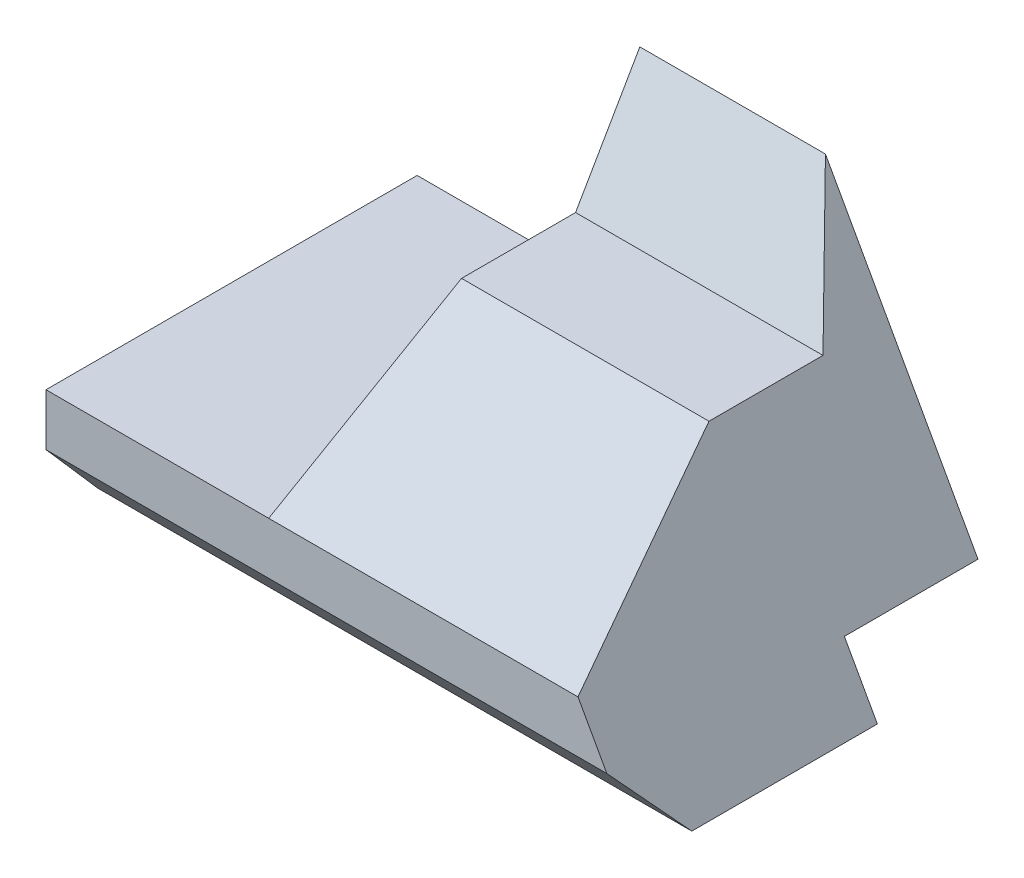
from build123d import *

# Parameters (mm, degrees)
BOSS_EXTRUDE3_DEPTH = 40
CUT_EXTRUDE1_DEPTH  = 51
CUT_EXTRUDE3_DEPTH  = 51


with BuildPart() as part:
    # Sketch8 → Boss-Extrude3 (new body, symmetric)
    with BuildSketch(Plane(origin=(0, 0, 0), x_dir=(0, 0, -1), z_dir=(1, 0, 0))):
        Polygon((-50, -30), (-50, -37), (-43, -45), (-18, -45), (-18, -37), (0, -37), (0, 0), (-8.660254038, -15), (-24.019237886, -15), align=None)
    extrude(amount=BOSS_EXTRUDE3_DEPTH, both=True)

    # Sketch10 → Cut-Extrude1 (cut, through all)
    with BuildSketch(Plane.XY.offset(50)):
        Polygon((-10, 0), (-40, 0), (-40, -15), (-40, -30), (-10, -30), align=None)
    extrude(amount=-CUT_EXTRUDE1_DEPTH, mode=Mode.SUBTRACT)

    # Sketch11 → Cut-Extrude3 (cut, through all)
    with BuildSketch(Plane.XY.offset(50)):
        Polygon((40, 0), (15, 0), (23.333333333, -15), (40, -15), align=None)
        Polygon((40, -15), (23.333333333, -15), (40, -45), (40, -37), (40, -30), align=None)
    extrude(amount=-CUT_EXTRUDE3_DEPTH, mode=Mode.SUBTRACT)


solid = part.part
